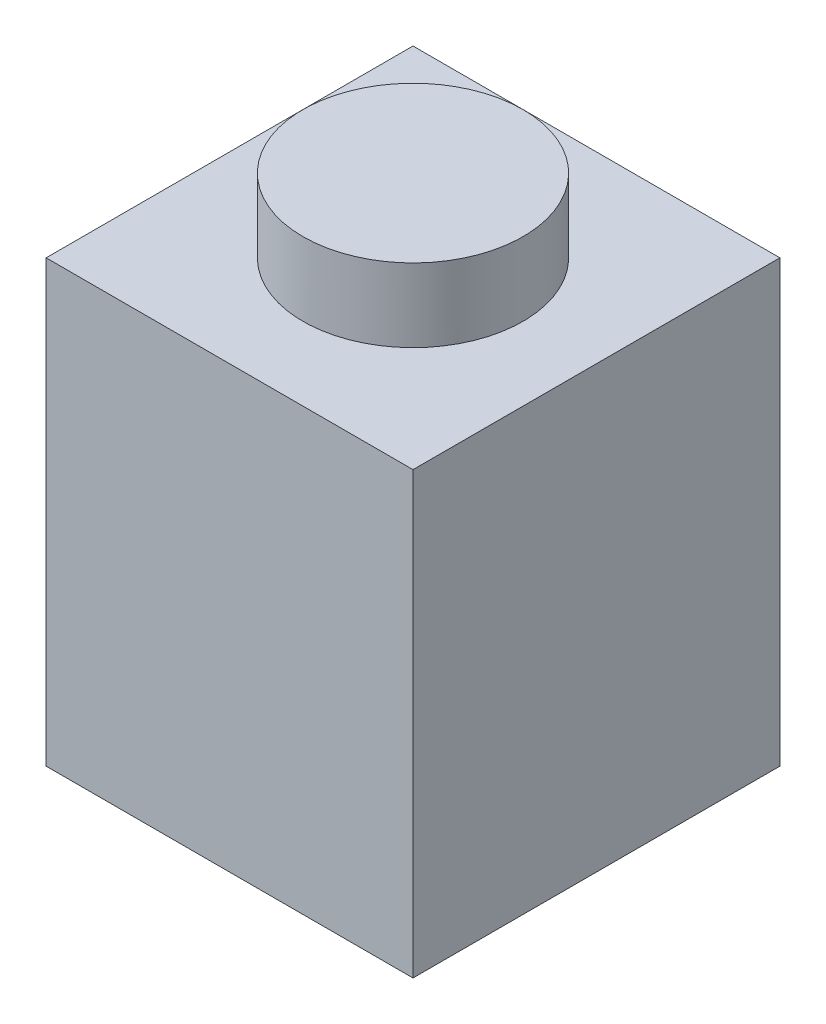
from build123d import *

# Parameters (mm, degrees)
SKETCH1_W           = 5
SKETCH1_H           = 5
SKETCH1_W_2         = 3
SKETCH1_H_2         = 3
BOSS_EXTRUDE1_DEPTH = 6
BOSS_EXTRUDE2_REACH = 6
SKETCH2_W           = 3
SKETCH2_H           = 1
BOSS_EXTRUDE3_DEPTH = 1
SKETCH4_R           = 0.75
CUT_EXTRUDE2_DEPTH  = 1


with BuildPart() as part:
    # Sketch1 → Boss-Extrude1 (new body)
    with BuildSketch(Plane(origin=(0, 0, 0), x_dir=(1, 0, 0), z_dir=(0, 1, 0))):
        with Locations((2.5, 2.5)):
            Rectangle(SKETCH1_W, SKETCH1_H)
        with Locations((2.5, 2.5)):
            Rectangle(SKETCH1_W_2, SKETCH1_H_2, mode=Mode.SUBTRACT)
    extrude(amount=BOSS_EXTRUDE1_DEPTH)

    # Sketch2 → Boss-Extrude2 (add, up to next)
    with BuildSketch(Plane.XY.offset(-4), mode=Mode.PRIVATE) as boss_extrude2_sk1:
        with Locations((2.5, 5.5)):
            Rectangle(SKETCH2_W, SKETCH2_H)
    boss_extrude2_tool1 = extrude(boss_extrude2_sk1.sketch, amount=BOSS_EXTRUDE2_REACH, mode=Mode.PRIVATE) - part.part
    add(boss_extrude2_tool1.solids().sort_by_distance((2.5, 5.5, -4))[0])

    # Sketch3 → Boss-Extrude3 (add)
    with BuildSketch(Plane(origin=(0, 6, 0), x_dir=(1, 0, 0), z_dir=(0, 1, 0))):
        with BuildLine():
            ThreePointArc((3.560660172, 3.560660172), (2.5, 4), (1.439339828, 3.560660172))
            Line((1.439339828, 3.560660172), (2.5, 2.5))
            Line((2.5, 2.5), (3.560660172, 3.560660172))
        make_face()
        with BuildLine():
            Line((2.5, 2.5), (1.439339828, 3.560660172))
            ThreePointArc((1.439339828, 3.560660172), (1, 2.5), (1.439339828, 1.439339828))
            Line((1.439339828, 1.439339828), (2.5, 2.5))
        make_face()
        with BuildLine():
            Line((3.560660172, 3.560660172), (2.5, 2.5))
            Line((2.5, 2.5), (3.560660172, 1.439339828))
            ThreePointArc((3.560660172, 1.439339828), (3.885819299, 1.925974851), (4, 2.5))
            ThreePointArc((4, 2.5), (3.885819299, 3.074025149), (3.560660172, 3.560660172))
        make_face()
        with BuildLine():
            Line((3.560660172, 1.439339828), (2.5, 2.5))
            Line((2.5, 2.5), (1.439339828, 1.439339828))
            ThreePointArc((1.439339828, 1.439339828), (2.5, 1), (3.560660172, 1.439339828))
        make_face()
    extrude(amount=BOSS_EXTRUDE3_DEPTH)

    # Sketch4 → Cut-Extrude2 (cut)
    with BuildSketch(Plane.XZ.offset(-5)):
        with Locations((2.5, -2.5)):
            Circle(SKETCH4_R)
    extrude(amount=-CUT_EXTRUDE2_DEPTH, mode=Mode.SUBTRACT)


solid = part.part
